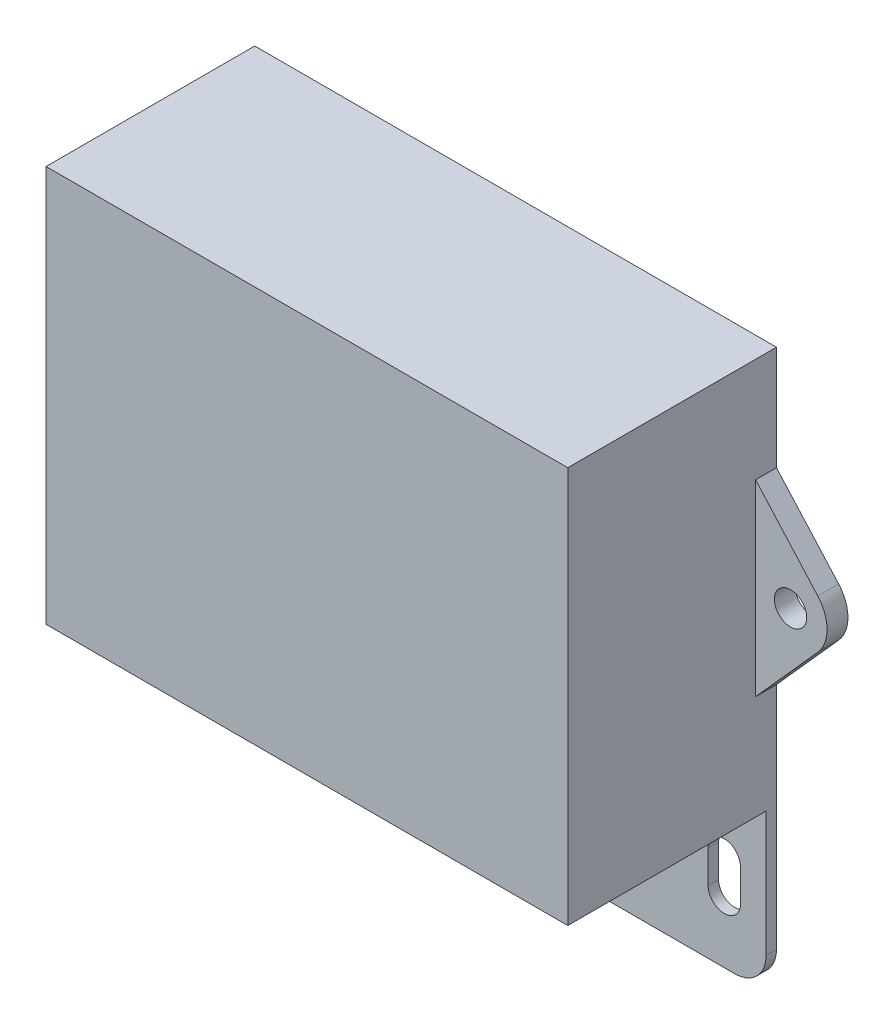
from build123d import *

# Parameters (mm, degrees)
SKETCH1_W                  = 50
SKETCH1_H                  = 38
MAIN_BODY_DEPTH            = 10
SIDE_MOUNTING_BODY_DEPTH   = 2
F_3_1_3_1_DIAMETER_HOLE1_D = 3.1
SKETCH5_W                  = 48
SKETCH5_H                  = 18
BOTTOM_CUT_DEPTH           = 2.6
SKETCH6_W                  = 50
SKETCH6_H                  = 1
BOTTOM_MOUNTING_TAB_DEPTH  = 15
SLOT_DEPTH                 = 2
FILLET1_R                  = 1.5
FILLET2_R                  = 3


with BuildPart() as part:
    # Sketch1 → MAIN BODY (new body, symmetric)
    with BuildSketch(Plane.XY):
        Rectangle(SKETCH1_W, SKETCH1_H)
    extrude(amount=MAIN_BODY_DEPTH, both=True)

    # Sketch2 → SIDE MOUNTING BODY (add)
    with BuildSketch(Plane(origin=(0, 0, -10), x_dir=(-1, 0, 0), z_dir=(0, 0, -1))):
        with BuildLine():
            Line((30.959543616, -2.332441235), (25, -9))
            Line((25, -9), (25, 9))
            Line((25, 9), (30.959543616, 2.332441235))
            ThreePointArc((30.959543616, 2.332441235), (31.85, 0), (30.959543616, -2.332441235))
        make_face()
    side_mounting_body = extrude(amount=-SIDE_MOUNTING_BODY_DEPTH)

    # Mirror1: SIDE MOUNTING BODY across plane
    add(side_mounting_body.mirror(Plane(origin=(0, 0, 0), x_dir=(0, 0, 1), z_dir=(1, 0, 0))))

    # Ø3.1 (3.1) Diameter Hole1 (through all)
    with Locations(Plane.XY.offset(-8)):
        with Locations((-28.35, 0), (28.35, 0)):
            Hole(F_3_1_3_1_DIAMETER_HOLE1_D / 2)

    # Sketch5 → BOTTOM CUT (cut)
    with BuildSketch(Plane(origin=(0, -19, 0), x_dir=(-1, 0, 0), z_dir=(0, -1, 0))):
        Rectangle(SKETCH5_W, SKETCH5_H)
    extrude(amount=-BOTTOM_CUT_DEPTH, mode=Mode.SUBTRACT)

    # Sketch6 → BOTTOM MOUNTING TAB (add)
    with BuildSketch(Plane(origin=(0, -19, 0), x_dir=(-1, 0, 0), z_dir=(0, -1, 0))):
        with Locations((0, 9.5)):
            Rectangle(SKETCH6_W, SKETCH6_H)
    extrude(amount=BOTTOM_MOUNTING_TAB_DEPTH)

    # Sketch7 → SLOT (cut, through all)
    with BuildSketch(Plane.XY.offset(-9)):
        with BuildLine():
            Line((-19.45, -24.85), (-19.45, -27.95))
            ThreePointArc((-19.45, -27.95), (-21, -29.5), (-22.55, -27.95))
            Line((-22.55, -27.95), (-22.55, -24.85))
            ThreePointArc((-22.55, -24.85), (-21, -23.3), (-19.45, -24.85))
        make_face()
    slot = extrude(amount=-SLOT_DEPTH, mode=Mode.SUBTRACT)

    # Mirror2: SLOT across plane
    add(slot.mirror(Plane(origin=(0, 0, 0), x_dir=(0, 0, 1), z_dir=(1, 0, 0))), mode=Mode.SUBTRACT)

    # Fillet1
    fillet1_edges = [part.edges().sort_by_distance(p)[0] for p in [
        (24, -16.4, 0),
        (24, -17.7, 9),
        (0, -16.4, -9),
        (24, -17.7, -9),
        (-24, -16.4, 0),
        (-24, -17.7, -9),
        (0, -16.4, 9),
        (-24, -17.7, 9),
    ]]
    fillet(fillet1_edges, radius=FILLET1_R)

    # Fillet2
    fillet2_edges = [part.edges().sort_by_distance(p)[0] for p in [
        (25, -34, -9.5),
        (-25, -34, -9.5),
    ]]
    fillet(fillet2_edges, radius=FILLET2_R)


solid = part.part
